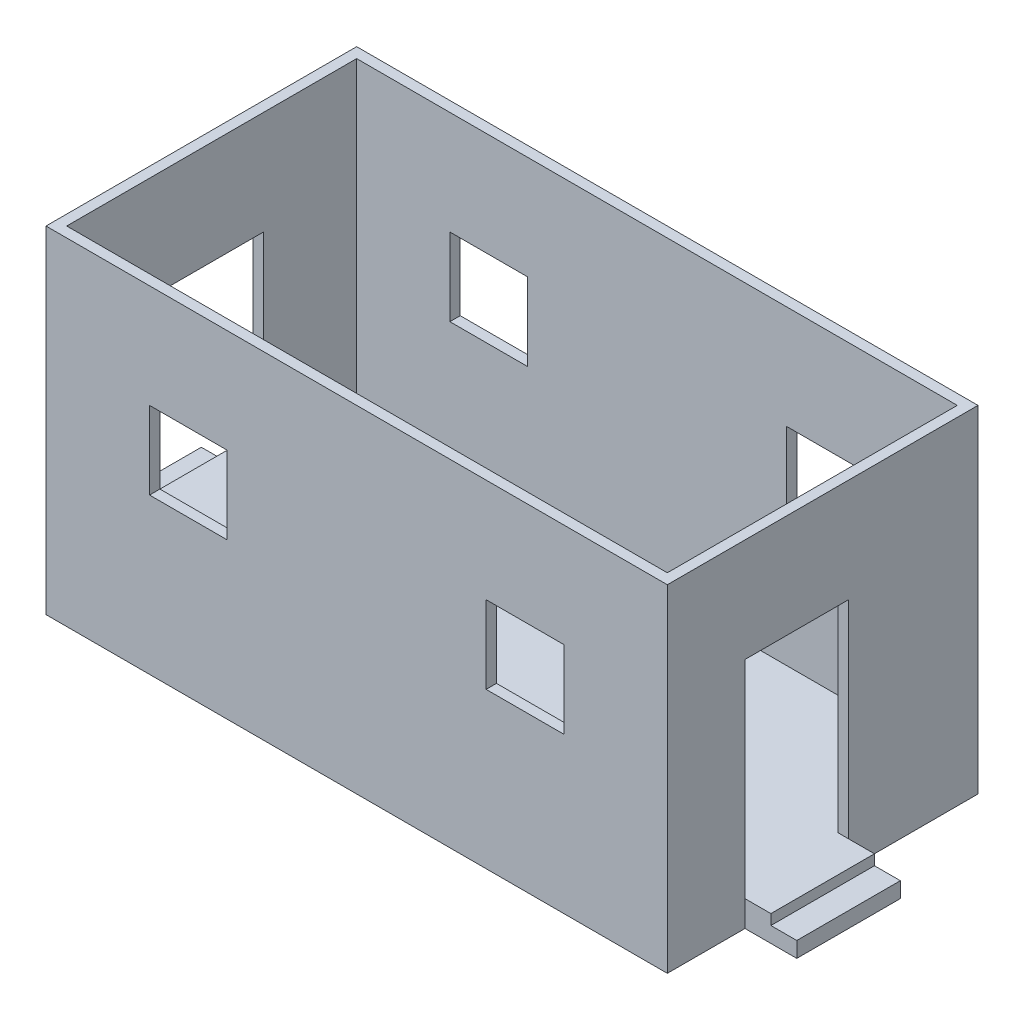
from build123d import *

# Parameters (mm, degrees)
SKETCH1_W           = 6000
SKETCH1_H           = 3000
BOSS_EXTRUDE1_DEPTH = 250
SKETCH2_W           = 6000
SKETCH2_H           = 3000
SKETCH2_W_2         = 5800
SKETCH2_H_2         = 2800
BOSS_EXTRUDE2_DEPTH = 3000
SKETCH3_W           = 1000
SKETCH3_H           = 2000
CUT_EXTRUDE1_DEPTH  = 250
SKETCH4_W           = 1000
SKETCH4_H           = 2000
CUT_EXTRUDE2_DEPTH  = 250
SKETCH5_W           = 750
SKETCH5_H           = 750
CUT_EXTRUDE3_DEPTH  = 3001
SKETCH6_W           = 1000
SKETCH6_H           = 250
BOSS_EXTRUDE4_DEPTH = 500
SKETCH7_W           = 1000
SKETCH7_H           = 250
BOSS_EXTRUDE5_DEPTH = 500
SKETCH8_W           = 250
SKETCH8_H           = 1000
CUT_EXTRUDE4_DEPTH  = 100
SKETCH9_W           = 250
SKETCH9_H           = 1000
CUT_EXTRUDE5_DEPTH  = 100


with BuildPart() as part:
    # Sketch1 → Boss-Extrude1 (new body)
    with BuildSketch(Plane(origin=(0, 0, 0), x_dir=(1, 0, 0), z_dir=(0, 1, 0))):
        Rectangle(SKETCH1_W, SKETCH1_H)
    extrude(amount=BOSS_EXTRUDE1_DEPTH)

    # Sketch2 → Boss-Extrude2 (add)
    with BuildSketch(Plane(origin=(0, 250, 0), x_dir=(1, 0, 0), z_dir=(0, 1, 0))):
        Rectangle(SKETCH2_W, SKETCH2_H)
        Rectangle(SKETCH2_W_2, SKETCH2_H_2, mode=Mode.SUBTRACT)
    extrude(amount=BOSS_EXTRUDE2_DEPTH)

    # Sketch3 → Cut-Extrude1 (cut)
    with BuildSketch(Plane.ZY.offset(3000)):
        with Locations((0, 1250)):
            Rectangle(SKETCH3_W, SKETCH3_H)
    extrude(amount=-CUT_EXTRUDE1_DEPTH, mode=Mode.SUBTRACT)

    # Sketch4 → Cut-Extrude2 (cut)
    with BuildSketch(Plane(origin=(3000, 0, 0), x_dir=(0, 0, -1), z_dir=(1, 0, 0))):
        with Locations((-250, 1250)):
            Rectangle(SKETCH4_W, SKETCH4_H)
    extrude(amount=-CUT_EXTRUDE2_DEPTH, mode=Mode.SUBTRACT)

    # Sketch5 → Cut-Extrude3 (cut, through all)
    with BuildSketch(Plane.XY.offset(1500)):
        with Locations((-1625, 1875)):
            Rectangle(SKETCH5_W, SKETCH5_H)
        with Locations((1625, 1875)):
            Rectangle(SKETCH5_W, SKETCH5_H)
    extrude(amount=-CUT_EXTRUDE3_DEPTH, mode=Mode.SUBTRACT)

    # Sketch6 → Boss-Extrude4 (add)
    with BuildSketch(Plane(origin=(3000, 0, 0), x_dir=(0, 0, -1), z_dir=(1, 0, 0))):
        with Locations((-250, 125)):
            Rectangle(SKETCH6_W, SKETCH6_H)
    extrude(amount=BOSS_EXTRUDE4_DEPTH)

    # Sketch7 → Boss-Extrude5 (add)
    with BuildSketch(Plane.ZY.offset(3000)):
        with Locations((0, 125)):
            Rectangle(SKETCH7_W, SKETCH7_H)
    extrude(amount=BOSS_EXTRUDE5_DEPTH)

    # Sketch8 → Cut-Extrude4 (cut)
    with BuildSketch(Plane(origin=(0, 250, 0), x_dir=(1, 0, 0), z_dir=(0, 1, 0))):
        with Locations((3375, -250)):
            Rectangle(SKETCH8_W, SKETCH8_H)
    extrude(amount=-CUT_EXTRUDE4_DEPTH, mode=Mode.SUBTRACT)

    # Sketch9 → Cut-Extrude5 (cut)
    with BuildSketch(Plane(origin=(0, 250, 0), x_dir=(1, 0, 0), z_dir=(0, 1, 0))):
        with Locations((-3375, 0)):
            Rectangle(SKETCH9_W, SKETCH9_H)
    extrude(amount=-CUT_EXTRUDE5_DEPTH, mode=Mode.SUBTRACT)


solid = part.part
